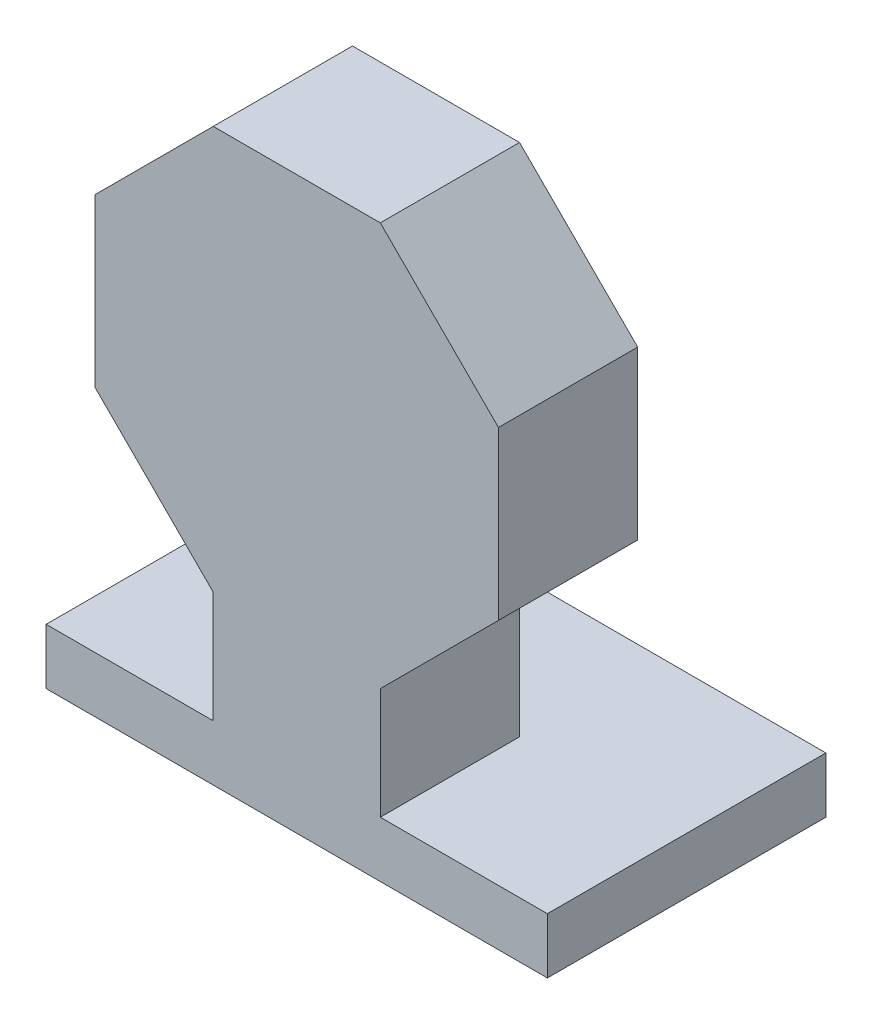
from build123d import *

# Parameters (mm, degrees)
EXTRUDE1_DEPTH = 25
SKETCH3_W      = 90
SKETCH3_H      = 50
EXTRUDE2_DEPTH = 10


with BuildPart() as part:
    # Sketch2 → Extrude1 (new body)
    with BuildSketch(Plane.XY):
        Polygon((15, -36.213203436), (15, -56.213203436), (-15, -56.213203436), (-15, -36.213203436), (-36.213203436, -15), (-36.213203436, 15), (-15, 36.213203436), (15, 36.213203436), (36.213203436, 15), (36.213203436, -15), align=None)
    extrude(amount=EXTRUDE1_DEPTH)

    # Sketch3 → Extrude2 (add)
    with BuildSketch(Plane.XZ.offset(56.213203436)):
        Rectangle(SKETCH3_W, SKETCH3_H)
    extrude(amount=EXTRUDE2_DEPTH)


solid = part.part
